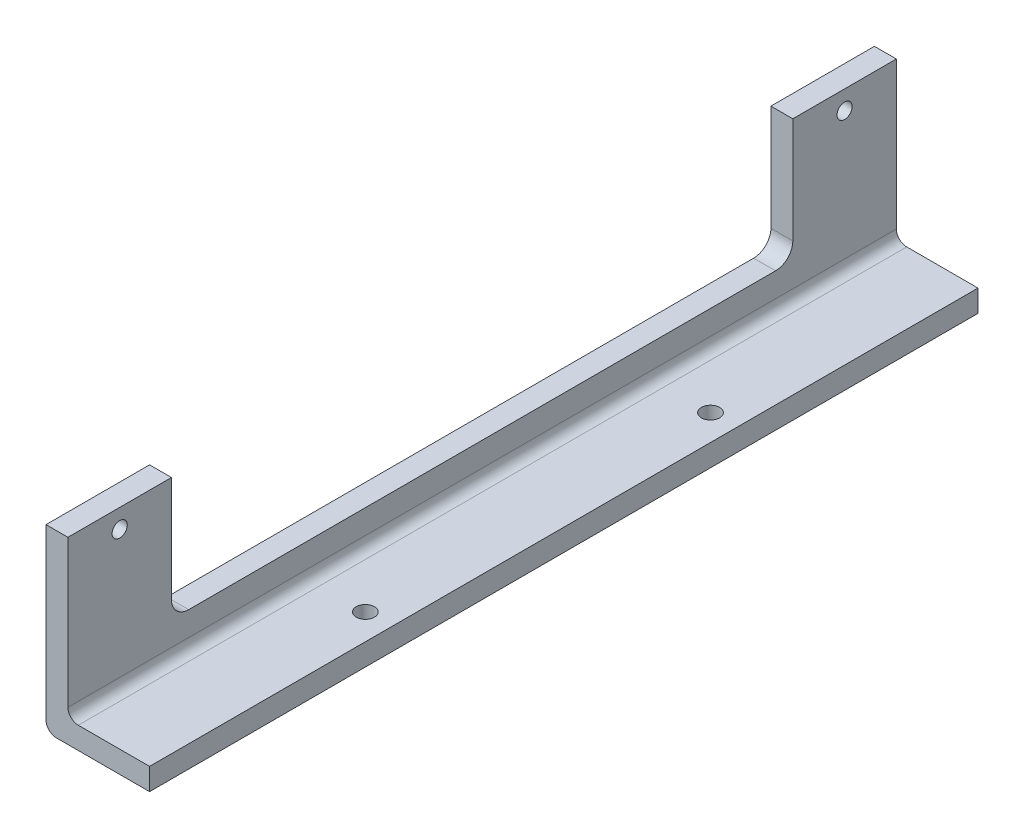
from build123d import *

# Parameters (mm, degrees)
EXTRUDE_THIN1_DEPTH                        = 240
SKETCH3_W                                  = 35
SKETCH3_H                                  = 300
EXTRUDE2_DEPTH                             = 7.35
SKETCH7_W                                  = 300
SKETCH7_H                                  = 30
EXTRUDE4_DEPTH                             = 7.35
EXTRUDE5_DEPTH                             = 7.35
TAPPED_HOLE_FOR_8_32_HELICOIL1_D           = 4.3942
TAPPED_HOLE_FOR_8_32_HELICOIL2_D           = 4.3942
TAPPED_HOLE_FOR_8_32_HELICOIL2_DEPTH       = 11.1252
TAPPED_HOLE_FOR_8_32_HELICOIL2_CBORE_D     = 5.27558
TAPPED_HOLE_FOR_8_32_HELICOIL2_CBORE_DEPTH = 5.08
TAPPED_HOLE_FOR_8_32_HELICOIL2_TIP         = 1.320150866
FILLET5_R                                  = 3


with BuildPart() as part:
    # Sketch1 → Extrude-Thin1 (new body)
    with BuildSketch(Plane.XY):
        Polygon((0, 55), (0, 0), (50.8, 0), (50.8, 6.35), (6.35, 6.35), (6.35, 55), align=None)
    extrude(amount=-EXTRUDE_THIN1_DEPTH)

    # Sketch3 → Extrude2 (cut, through all)
    with BuildSketch(Plane(origin=(0, 6.35, 0), x_dir=(1, 0, 0), z_dir=(0, 1, 0))):
        with Locations((47.5, 95)):
            Rectangle(SKETCH3_W, SKETCH3_H)
    extrude(amount=-EXTRUDE2_DEPTH, mode=Mode.SUBTRACT)

    # Sketch7 → Extrude4 (cut, through all)
    with BuildSketch(Plane(origin=(6.35, 0, 0), x_dir=(0, 0, -1), z_dir=(1, 0, 0))):
        with Locations((145, 67)):
            Rectangle(SKETCH7_W, SKETCH7_H)
    extrude(amount=-EXTRUDE4_DEPTH, mode=Mode.SUBTRACT)

    # Sketch10 → Extrude5 (cut, through all)
    with BuildSketch(Plane(origin=(6.35, 0, 0), x_dir=(0, 0, -1), z_dir=(1, 0, 0))):
        with BuildLine():
            Line((30, 66.35), (210, 66.35))
            Line((210, 66.35), (210, 21.35))
            ThreePointArc((210, 21.35), (208.535533906, 17.814466094), (205, 16.35))
            Line((205, 16.35), (35, 16.35))
            ThreePointArc((35, 16.35), (31.464466094, 17.814466094), (30, 21.35))
            Line((30, 21.35), (30, 66.35))
        make_face()
    extrude(amount=-EXTRUDE5_DEPTH, mode=Mode.SUBTRACT)

    # Tapped Hole for #8-32 Helicoil1 (through all)
    with Locations(Plane(origin=(6.35, 46.5, -15), x_dir=(0, 0, 1), z_dir=(1, 0, 0))):
        with Locations((0, 0), (-210, 0)):
            Hole(TAPPED_HOLE_FOR_8_32_HELICOIL1_D / 2)

    # Tapped Hole for #8-32 Helicoil2
    with Locations(Plane(origin=(22.5, 6.35, -70), x_dir=(0, 0, 1), z_dir=(0, 1, 0))):
        with Locations((0, 0), (-100, 0)):
            CounterBoreHole(TAPPED_HOLE_FOR_8_32_HELICOIL2_D / 2, TAPPED_HOLE_FOR_8_32_HELICOIL2_CBORE_D / 2, TAPPED_HOLE_FOR_8_32_HELICOIL2_CBORE_DEPTH, depth=TAPPED_HOLE_FOR_8_32_HELICOIL2_DEPTH)
            with Locations((0, 0, -(TAPPED_HOLE_FOR_8_32_HELICOIL2_DEPTH + TAPPED_HOLE_FOR_8_32_HELICOIL2_TIP / 2))):  # 118° drill point
                Cone(0, TAPPED_HOLE_FOR_8_32_HELICOIL2_D / 2, TAPPED_HOLE_FOR_8_32_HELICOIL2_TIP, mode=Mode.SUBTRACT)

    # Fillet5
    fillet5_edges = [part.edges().sort_by_distance(p)[0] for p in [
        (6.35, 6.35, -120),
        (0, 0, -120),
    ]]
    fillet(fillet5_edges, radius=FILLET5_R)


solid = part.part
